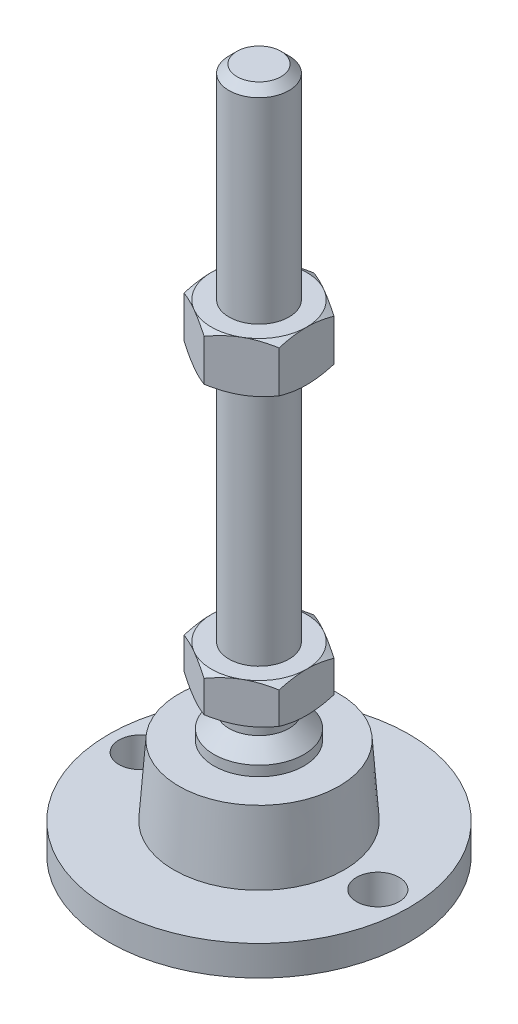
from build123d import *

# Parameters (mm, degrees)
EXTRUDE_1_DEPTH     = 8
EXTRUDE_2_DEPTH     = 10
SKETCH_5_R          = 4.25
CUT_EXTRUDE_1_DEPTH = 7


with BuildPart() as part:
    # Эскиз1 → Повернуть1 (revolve)
    with BuildSketch(Plane.XY, mode=Mode.PRIVATE) as revolve_1_sk:
        Polygon((0, 0), (-30, 0), (-30, 6), (-17, 6), (-16, 20), (-9, 20), (-9, 22), (-6, 25), (-6, 29), (-6, 37), (-6, 135.4), (-4.4, 137), (0, 137), align=None)
    revolve(revolve_1_sk.sketch.rotate(Axis((0, 0, 0), (0, 1, 0)), 180), axis=Axis((0, 0, 0), (0, 1, 0)))  # turned: the seam where the file's is

    # Эскиз2 → Бобышка-Вытянуть1 (add)
    with BuildSketch(Plane(origin=(0, 29, 0), x_dir=(1, 0, 0), z_dir=(0, 1, 0))):
        Polygon((0, 10.969655115), (-9.5, 5.484827557), (-9.5, -5.484827557), (0, -10.969655115), (9.5, -5.484827557), (9.5, 5.484827557), align=None)
    extrude(amount=EXTRUDE_1_DEPTH)

    # Эскиз3 → Бобышка-Вытянуть2 (add)
    with BuildSketch(Plane(origin=(0, 86.2, 0), x_dir=(1, 0, 0), z_dir=(0, 1, 0))):
        Polygon((9.5, 5.484827557), (0, 10.969655115), (-9.5, 5.484827557), (-9.5, -5.484827557), (0, -10.969655115), (9.5, -5.484827557), align=None)
    extrude(amount=EXTRUDE_2_DEPTH)

    # Эскиз4 → Вырез-Повернуть2 (revolve, cut)
    with BuildSketch(Plane.XY, mode=Mode.PRIVATE) as cut_revolve_2_sk:
        Polygon((-18.160254038, 96.2), (-9.5, 96.2), (-18.160254038, 91.2), align=None)
        Polygon((-18.160254038, 86.2), (-18.160254038, 91.2), (-9.5, 86.2), align=None)
        Polygon((-16.42820323, 37), (-16.42820323, 33), (-9.5, 37), align=None)
        Polygon((-16.42820323, 33), (-16.42820323, 29), (-9.5, 29), align=None)
    revolve(cut_revolve_2_sk.sketch.rotate(Axis((0, 137, 0), (0, -1, 0)), 180), axis=Axis((0, 137, 0), (0, -1, 0)), mode=Mode.SUBTRACT)  # turned: the seam where the file's is

    # Эскиз5 → Вырез-Вытянуть1 (cut, through all)
    with BuildSketch(Plane(origin=(0, 6, 0), x_dir=(1, 0, 0), z_dir=(0, 1, 0))):
        with Locations(Location((-23.75, 0, 0), (0, 0, 180))):  # turned: the seam where the file's is
            Circle(SKETCH_5_R)
        with Locations(Location((23.75, 0, 0), (0, 0, 180))):  # turned: the seam where the file's is
            Circle(SKETCH_5_R)
    extrude(amount=-CUT_EXTRUDE_1_DEPTH, mode=Mode.SUBTRACT)


solid = part.part
